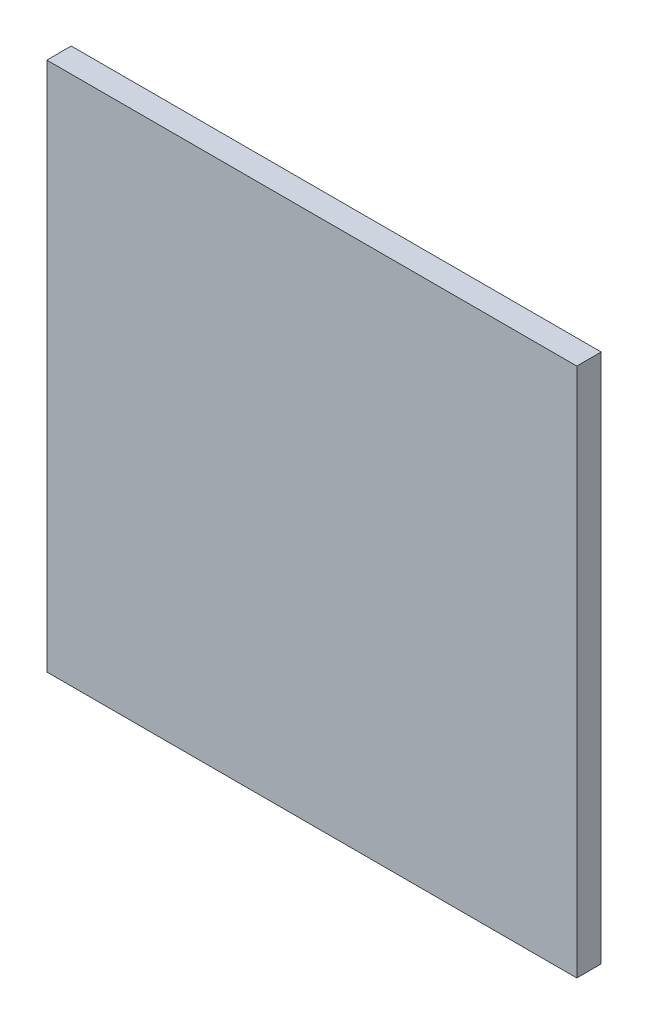
from build123d import *

# Parameters (mm, degrees)
SKETCH_1_W      = 50
SKETCH_1_H      = 50
EXTRUDE_1_DEPTH = 2.3


with BuildPart() as part:
    # 草图1 → 凸台-拉伸1 (new body)
    with BuildSketch(Plane.XY):
        with Locations((202.495871552, 123.126483669)):
            Rectangle(SKETCH_1_W, SKETCH_1_H)
    extrude(amount=EXTRUDE_1_DEPTH)


solid = part.part
